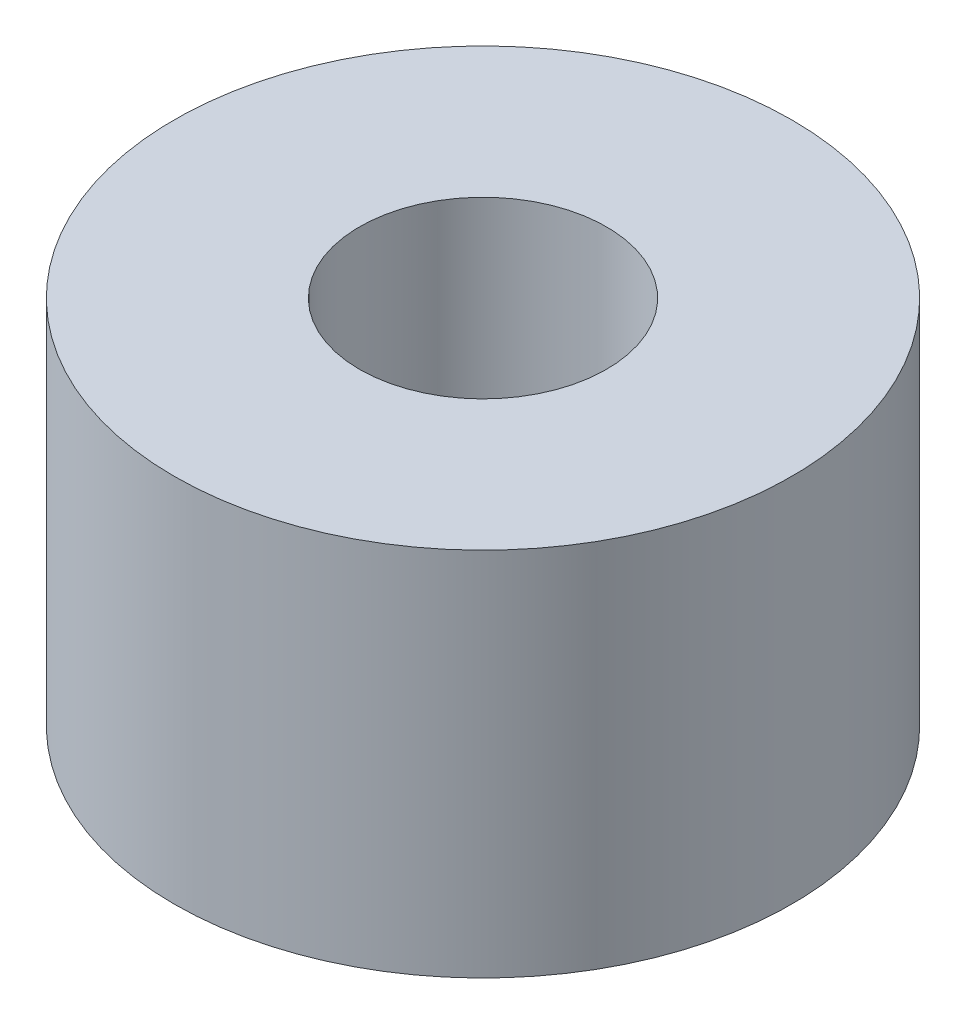
from build123d import *

# Parameters (mm, degrees)
SKETCH1_R           = 10
SKETCH1_R_2         = 4
BOSS_EXTRUDE1_DEPTH = 12


with BuildPart() as part:
    # Sketch1 → Boss-Extrude1 (new body)
    with BuildSketch(Plane(origin=(0, 0, 0), x_dir=(1, 0, 0), z_dir=(0, 1, 0))):
        Circle(SKETCH1_R)
        Circle(SKETCH1_R_2, mode=Mode.SUBTRACT)
    extrude(amount=-BOSS_EXTRUDE1_DEPTH)


solid = part.part
